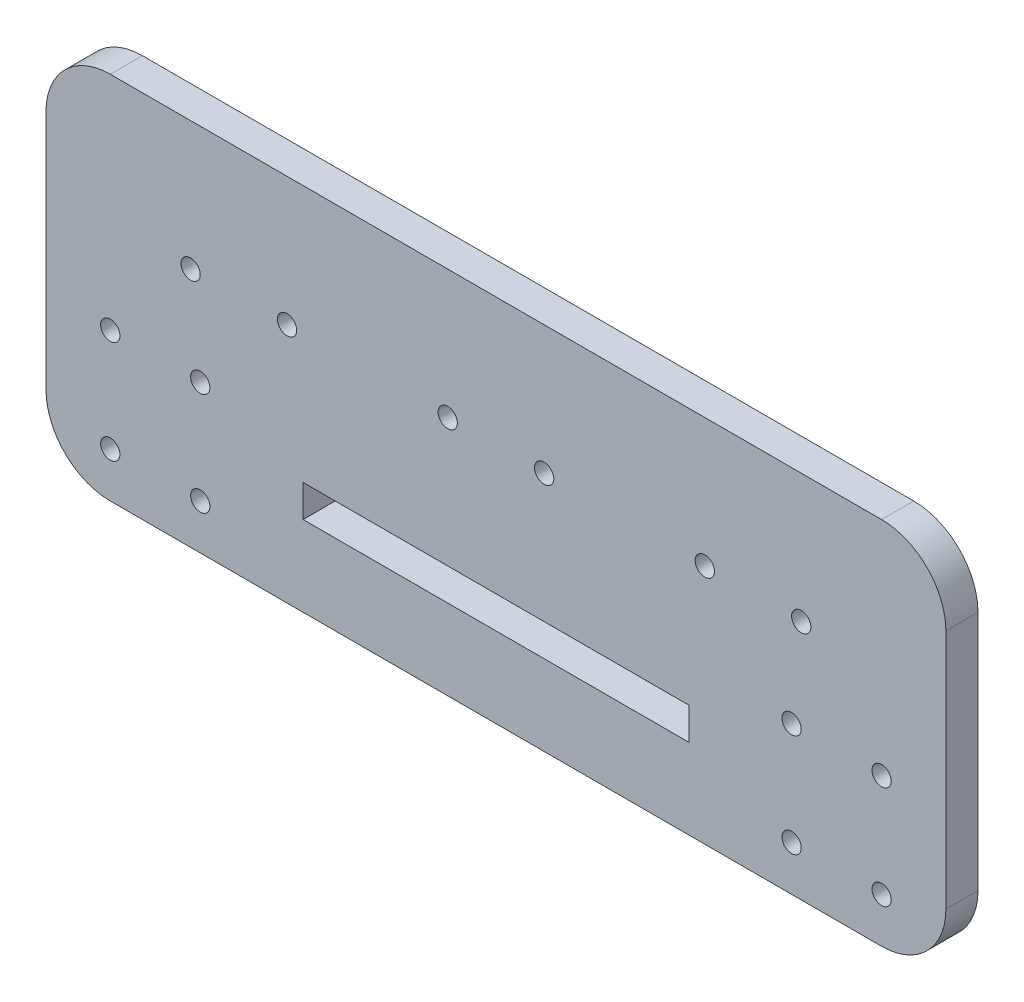
from build123d import *

# Parameters (mm, degrees)
BOSS_EXTRUDE1_DEPTH = 5
SKETCH2_R           = 1.5
SKETCH2_W           = 60
SKETCH2_H           = 5
CUT_EXTRUDE1_DEPTH  = 5
SKETCH4_R           = 1.5
CUT_EXTRUDE2_DEPTH  = 5


with BuildPart() as part:
    # Sketch1 → Boss-Extrude1 (new body)
    with BuildSketch(Plane.XY):
        with BuildLine():
            Line((-60, 28.75), (60, 28.75))
            ThreePointArc((60, 28.75), (67.071067812, 25.821067812), (70, 18.75))
            Line((70, 18.75), (70, -18.75))
            ThreePointArc((70, -18.75), (67.071067812, -25.821067812), (60, -28.75))
            Line((60, -28.75), (-60, -28.75))
            ThreePointArc((-60, -28.75), (-67.071067812, -25.821067812), (-70, -18.75))
            Line((-70, -18.75), (-70, 18.75))
            ThreePointArc((-70, 18.75), (-67.071067812, 25.821067812), (-60, 28.75))
        make_face()
    extrude(amount=BOSS_EXTRUDE1_DEPTH)

    # Sketch2 → Cut-Extrude1 (cut)
    with BuildSketch(Plane.XY.offset(5)):
        with Locations((60, -5.75)):
            Circle(SKETCH2_R)
        with Locations((46, -5.75)):
            Circle(SKETCH2_R)
        with Locations((46, -21.75)):
            Circle(SKETCH2_R)
        with Locations((60, -21.75)):
            Circle(SKETCH2_R)
        with Locations((-46, -5.75)):
            Circle(SKETCH2_R)
        with Locations((-46, -21.75)):
            Circle(SKETCH2_R)
        with Locations((-60, -21.75)):
            Circle(SKETCH2_R)
        with Locations((-60, -5.75)):
            Circle(SKETCH2_R)
        with Locations((0, -13.75)):
            Rectangle(SKETCH2_W, SKETCH2_H)
    extrude(amount=-CUT_EXTRUDE1_DEPTH, mode=Mode.SUBTRACT)

    # Sketch4 → Cut-Extrude2 (cut)
    with BuildSketch(Plane.XY.offset(5)):
        with Locations((7.5, 8.75)):
            Circle(SKETCH4_R)
        with Locations((-7.5, 8.75)):
            Circle(SKETCH4_R)
        with Locations((47.5, 8.75)):
            Circle(SKETCH4_R)
        with Locations((32.5, 8.75)):
            Circle(SKETCH4_R)
        with Locations((-32.5, 8.75)):
            Circle(SKETCH4_R)
        with Locations((-47.5, 8.75)):
            Circle(SKETCH4_R)
    extrude(amount=-CUT_EXTRUDE2_DEPTH, mode=Mode.SUBTRACT)


solid = part.part
